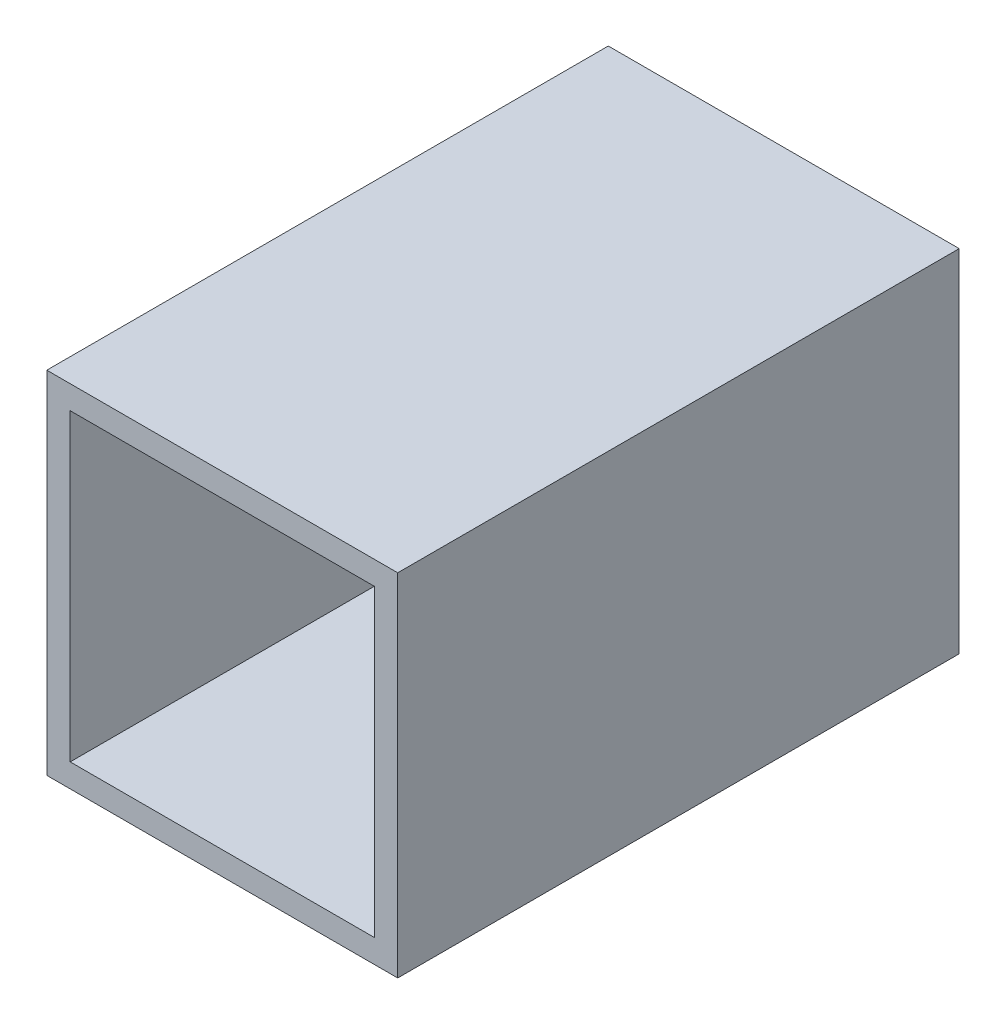
from build123d import *

# Parameters (mm, degrees)
SKETCH1_W           = 38.1
SKETCH1_H           = 38.1
SKETCH1_W_2         = 33.02
SKETCH1_H_2         = 33.02
BOSS_EXTRUDE1_DEPTH = 60.96


with BuildPart() as part:
    # Sketch1 → Boss-Extrude1 (new body)
    with BuildSketch(Plane.XY):
        with Locations((-17.749998475, -3.91903616)):
            Rectangle(SKETCH1_W, SKETCH1_H)
        with Locations((-17.749998475, -3.91903616)):
            Rectangle(SKETCH1_W_2, SKETCH1_H_2, mode=Mode.SUBTRACT)
    extrude(amount=BOSS_EXTRUDE1_DEPTH)


solid = part.part
